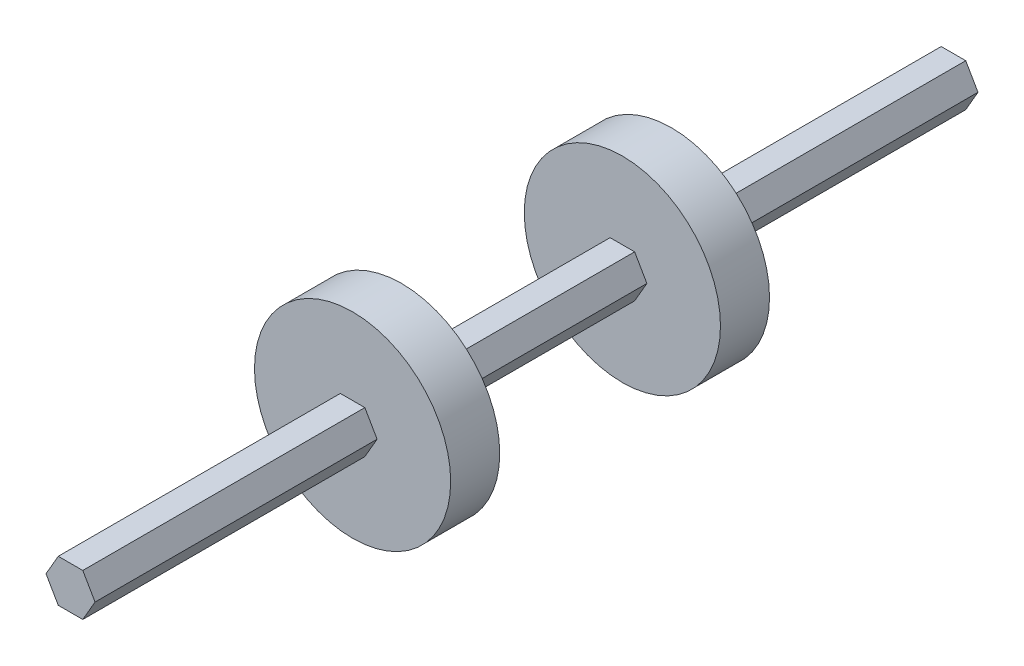
from build123d import *

# Parameters (mm, degrees)
BOSS_EXTRUDE1_DEPTH = 228.6
SKETCH2_R           = 25.4
BOSS_EXTRUDE2_DEPTH = 12.7
SKETCH3_R           = 25.4
BOSS_EXTRUDE3_DEPTH = 12.7


with BuildPart() as part:
    # Sketch1 → Boss-Extrude1 (new body)
    with BuildSketch(Plane.XY):
        Polygon((-3.175, 5.499261314), (-6.35, 0), (-3.175, -5.499261314), (3.175, -5.499261314), (6.35, 0), (3.175, 5.499261314), align=None)
    extrude(amount=BOSS_EXTRUDE1_DEPTH)

    # Sketch2 → Boss-Extrude2 (add)
    with BuildSketch(Plane.XY.offset(85.725)):
        Circle(SKETCH2_R)
    extrude(amount=-BOSS_EXTRUDE2_DEPTH)

    # Sketch3 → Boss-Extrude3 (add)
    with BuildSketch(Plane.XY.offset(142.875)):
        Circle(SKETCH3_R)
    extrude(amount=BOSS_EXTRUDE3_DEPTH)


solid = part.part
